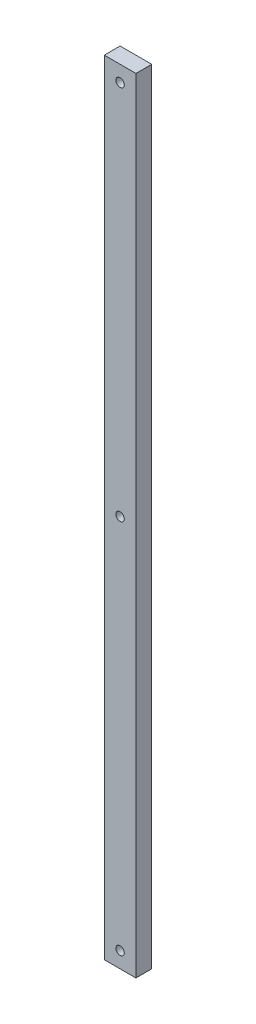
from build123d import *

# Parameters (mm, degrees)
SKETCH1_W           = 25.4
SKETCH1_H           = 628.65
BOSS_EXTRUDE1_DEPTH = 12.7
SKETCH2_R           = 3.3655
CUT_EXTRUDE1_DEPTH  = 13.7
LPATTERN1_COUNT     = 3
LPATTERN1_PITCH     = 301.625


with BuildPart() as part:
    # Sketch1 → Boss-Extrude1 (new body)
    with BuildSketch(Plane.XY):
        with Locations((-12.7, 314.325)):
            Rectangle(SKETCH1_W, SKETCH1_H)
    extrude(amount=BOSS_EXTRUDE1_DEPTH)

    # Sketch2 → Cut-Extrude1 (cut, through all)
    with BuildSketch(Plane.XY.offset(12.7)):
        with Locations((-12.7, 12.7)):
            Circle(SKETCH2_R)
    cut_extrude1 = extrude(amount=-CUT_EXTRUDE1_DEPTH, mode=Mode.SUBTRACT)

    # LPattern1: Cut-Extrude1 ×3
    with Locations(*[(0, i * LPATTERN1_PITCH, 0) for i in range(1, LPATTERN1_COUNT)]):
        add(cut_extrude1, mode=Mode.SUBTRACT)


solid = part.part
